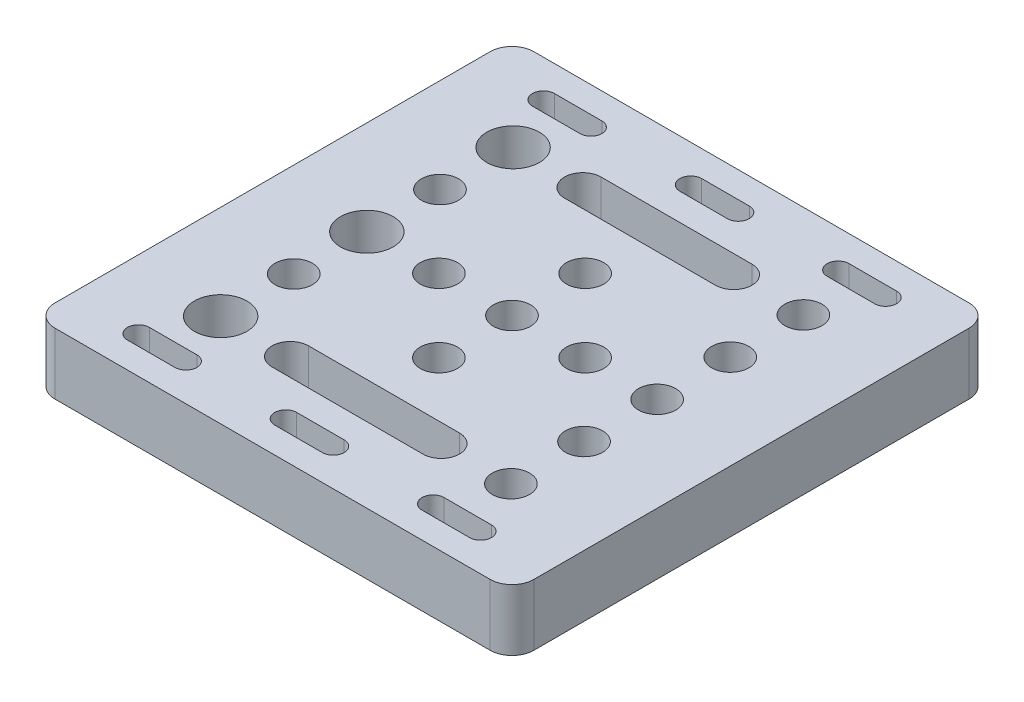
from build123d import *

# Parameters (mm, degrees)
SKETCH1_R           = 2.55
SKETCH1_R_2         = 3.6
BOSS_EXTRUDE1_DEPTH = 8.4


with BuildPart() as part:
    # Sketch1 → Boss-Extrude1 (new body)
    with BuildSketch(Plane(origin=(0, 0, 0), x_dir=(1, 0, 0), z_dir=(0, 1, 0))):
        with BuildLine():
            Line((29.75, -32.75), (-29.75, -32.75))
            ThreePointArc((-29.75, -32.75), (-31.871320344, -31.871320344), (-32.75, -29.75))
            Line((-32.75, -29.75), (-32.75, 29.75))
            ThreePointArc((-32.75, 29.75), (-31.871320344, 31.871320344), (-29.75, 32.75))
            Line((-29.75, 32.75), (29.75, 32.75))
            ThreePointArc((29.75, 32.75), (31.871320344, 31.871320344), (32.75, 29.75))
            Line((32.75, 29.75), (32.75, -29.75))
            ThreePointArc((32.75, -29.75), (31.871320344, -31.871320344), (29.75, -32.75))
        make_face()
        with Locations((0, 10)):
            Circle(SKETCH1_R, mode=Mode.SUBTRACT)
        Circle(SKETCH1_R, mode=Mode.SUBTRACT)
        with Locations((10, 0)):
            Circle(SKETCH1_R, mode=Mode.SUBTRACT)
        with Locations((-10, 0)):
            Circle(SKETCH1_R, mode=Mode.SUBTRACT)
        with Locations((-19.85, 20)):
            Circle(SKETCH1_R_2, mode=Mode.SUBTRACT)
        with Locations((-19.85, 0)):
            Circle(SKETCH1_R_2, mode=Mode.SUBTRACT)
        with Locations((-19.85, -20)):
            Circle(SKETCH1_R_2, mode=Mode.SUBTRACT)
        with Locations((-19.85, 10)):
            Circle(SKETCH1_R, mode=Mode.SUBTRACT)
        with Locations((19.85, 20)):
            Circle(SKETCH1_R, mode=Mode.SUBTRACT)
        with Locations((19.85, 0)):
            Circle(SKETCH1_R, mode=Mode.SUBTRACT)
        with Locations((19.85, -20)):
            Circle(SKETCH1_R, mode=Mode.SUBTRACT)
        with Locations((0, -10)):
            Circle(SKETCH1_R, mode=Mode.SUBTRACT)
        with Locations((19.85, 10)):
            Circle(SKETCH1_R, mode=Mode.SUBTRACT)
        with Locations((19.85, -10)):
            Circle(SKETCH1_R, mode=Mode.SUBTRACT)
        with Locations((-19.85, -10)):
            Circle(SKETCH1_R, mode=Mode.SUBTRACT)
        with BuildLine():
            Line((10.32, 17.5), (-10.32, 17.5))
            ThreePointArc((-10.32, 17.5), (-12.82, 20), (-10.32, 22.5))
            Line((-10.32, 22.5), (10.32, 22.5))
            ThreePointArc((10.32, 22.5), (12.82, 20), (10.32, 17.5))
        make_face(mode=Mode.SUBTRACT)
        with BuildLine():
            Line((3.25, 26.2), (-3.25, 26.2))
            ThreePointArc((-3.25, 26.2), (-4.75, 27.7), (-3.25, 29.2))
            Line((-3.25, 29.2), (3.25, 29.2))
            ThreePointArc((3.25, 29.2), (4.75, 27.7), (3.25, 26.2))
        make_face(mode=Mode.SUBTRACT)
        with BuildLine():
            Line((-16.9, 26.2), (-23.4, 26.2))
            ThreePointArc((-23.4, 26.2), (-24.9, 27.7), (-23.4, 29.2))
            Line((-23.4, 29.2), (-16.9, 29.2))
            ThreePointArc((-16.9, 29.2), (-15.4, 27.7), (-16.9, 26.2))
        make_face(mode=Mode.SUBTRACT)
        with BuildLine():
            Line((16.9, 26.2), (23.4, 26.2))
            ThreePointArc((23.4, 26.2), (24.9, 27.7), (23.4, 29.2))
            Line((23.4, 29.2), (16.9, 29.2))
            ThreePointArc((16.9, 29.2), (15.4, 27.7), (16.9, 26.2))
        make_face(mode=Mode.SUBTRACT)
        with BuildLine():
            Line((10.32, -17.5), (-10.32, -17.5))
            ThreePointArc((-10.32, -17.5), (-12.82, -20), (-10.32, -22.5))
            Line((-10.32, -22.5), (10.32, -22.5))
            ThreePointArc((10.32, -22.5), (12.82, -20), (10.32, -17.5))
        make_face(mode=Mode.SUBTRACT)
        with BuildLine():
            Line((-16.9, -26.2), (-23.4, -26.2))
            ThreePointArc((-23.4, -26.2), (-24.9, -27.7), (-23.4, -29.2))
            Line((-23.4, -29.2), (-16.9, -29.2))
            ThreePointArc((-16.9, -29.2), (-15.4, -27.7), (-16.9, -26.2))
        make_face(mode=Mode.SUBTRACT)
        with BuildLine():
            Line((3.25, -26.2), (-3.25, -26.2))
            ThreePointArc((-3.25, -26.2), (-4.75, -27.7), (-3.25, -29.2))
            Line((-3.25, -29.2), (3.25, -29.2))
            ThreePointArc((3.25, -29.2), (4.75, -27.7), (3.25, -26.2))
        make_face(mode=Mode.SUBTRACT)
        with BuildLine():
            Line((16.9, -26.2), (23.4, -26.2))
            ThreePointArc((23.4, -26.2), (24.9, -27.7), (23.4, -29.2))
            Line((23.4, -29.2), (16.9, -29.2))
            ThreePointArc((16.9, -29.2), (15.4, -27.7), (16.9, -26.2))
        make_face(mode=Mode.SUBTRACT)
    extrude(amount=BOSS_EXTRUDE1_DEPTH)


solid = part.part
